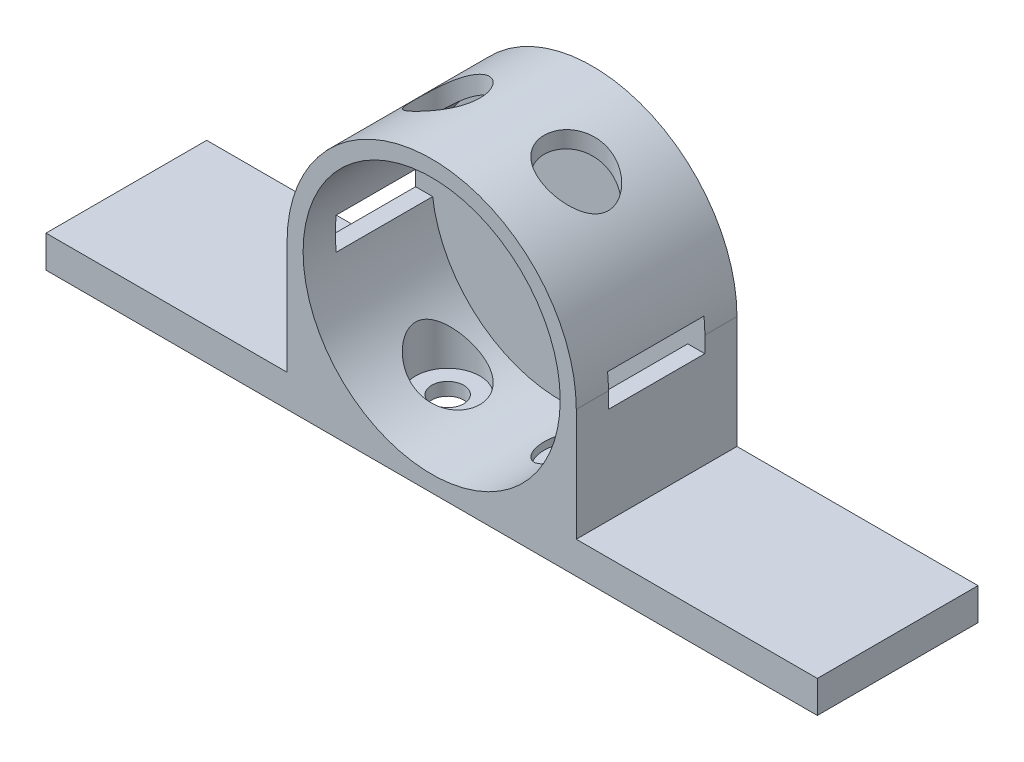
from build123d import *

# Parameters (mm, degrees)
SKETCH2_R           = 22.5
BOSS_EXTRUDE3_DEPTH = 25
SKETCH6_W           = 45
SKETCH6_H           = 22.5
BOSS_EXTRUDE4_DEPTH = 25
SKETCH4_R           = 20
CUT_EXTRUDE1_DEPTH  = 20
SKETCH5_R           = 2.5
CUT_EXTRUDE2_DEPTH  = 5
SKETCH7_R           = 5
CUT_EXTRUDE6_DEPTH  = 46
SKETCH9_R           = 5
SKETCH9_R_2         = 2.5
BOSS_EXTRUDE5_DEPTH = 2
SKETCH14_W          = 15
SKETCH14_H          = 5
CUT_EXTRUDE8_DEPTH  = 46.0000001
SKETCH15_W          = 25
SKETCH15_H          = 5
BOSS_EXTRUDE6_DEPTH = 37.5
SKETCH16_W          = 25
SKETCH16_H          = 5
BOSS_EXTRUDE7_DEPTH = 37.5


with BuildPart() as part:
    # Sketch2 → Boss-Extrude3 (new body)
    with BuildSketch(Plane.XY):
        Circle(SKETCH2_R)
    extrude(amount=BOSS_EXTRUDE3_DEPTH)

    # Sketch6 → Boss-Extrude4 (add)
    with BuildSketch(Plane.XY):
        with Locations((0, -11.25)):
            Rectangle(SKETCH6_W, SKETCH6_H)
    extrude(amount=BOSS_EXTRUDE4_DEPTH)

    # Sketch4 → Cut-Extrude1 (cut)
    with BuildSketch(Plane.XY.offset(25)):
        Circle(SKETCH4_R)
    extrude(amount=-CUT_EXTRUDE1_DEPTH, mode=Mode.SUBTRACT)

    # Sketch5 → Cut-Extrude2 (cut)
    with BuildSketch(Plane(origin=(0, 0, 0), x_dir=(-1, 0, 0), z_dir=(0, 0, -1))):
        Circle(SKETCH5_R)
    extrude(amount=-CUT_EXTRUDE2_DEPTH, mode=Mode.SUBTRACT)

    # Sketch7 → Cut-Extrude6 (cut, through all)
    with BuildSketch(Plane.XZ.offset(22.5)):
        with Locations((-10, 12.5)):
            Circle(SKETCH7_R)
        with Locations((10, 12.5)):
            Circle(SKETCH7_R)
    extrude(amount=-CUT_EXTRUDE6_DEPTH, mode=Mode.SUBTRACT)

    # Sketch9 → Boss-Extrude5 (add)
    with BuildSketch(Plane.XZ.offset(22.5)):
        with Locations((-10, 12.5)):
            Circle(SKETCH9_R)
        with Locations((-10, 12.5)):
            Circle(SKETCH9_R_2, mode=Mode.SUBTRACT)
        with Locations((10, 12.5)):
            Circle(SKETCH9_R)
        with Locations((10, 12.5)):
            Circle(SKETCH9_R_2, mode=Mode.SUBTRACT)
    extrude(amount=-BOSS_EXTRUDE5_DEPTH)

    # Sketch14 → Cut-Extrude8 (cut, through all)
    with BuildSketch(Plane(origin=(22.5, 0, 0), x_dir=(0, 0, -1), z_dir=(1, 0, 0))):
        with Locations((-12.5, 0)):
            Rectangle(SKETCH14_W, SKETCH14_H)
    extrude(amount=-CUT_EXTRUDE8_DEPTH, mode=Mode.SUBTRACT)

    # Sketch15 → Boss-Extrude6 (add)
    with BuildSketch(Plane.ZY.offset(22.5)):
        with Locations((12.5, -20)):
            Rectangle(SKETCH15_W, SKETCH15_H)
    extrude(amount=BOSS_EXTRUDE6_DEPTH)

    # Sketch16 → Boss-Extrude7 (add)
    with BuildSketch(Plane(origin=(22.5, 0, 0), x_dir=(0, 0, -1), z_dir=(1, 0, 0))):
        with Locations((-12.5, -20)):
            Rectangle(SKETCH16_W, SKETCH16_H)
    extrude(amount=BOSS_EXTRUDE7_DEPTH)


solid = part.part
